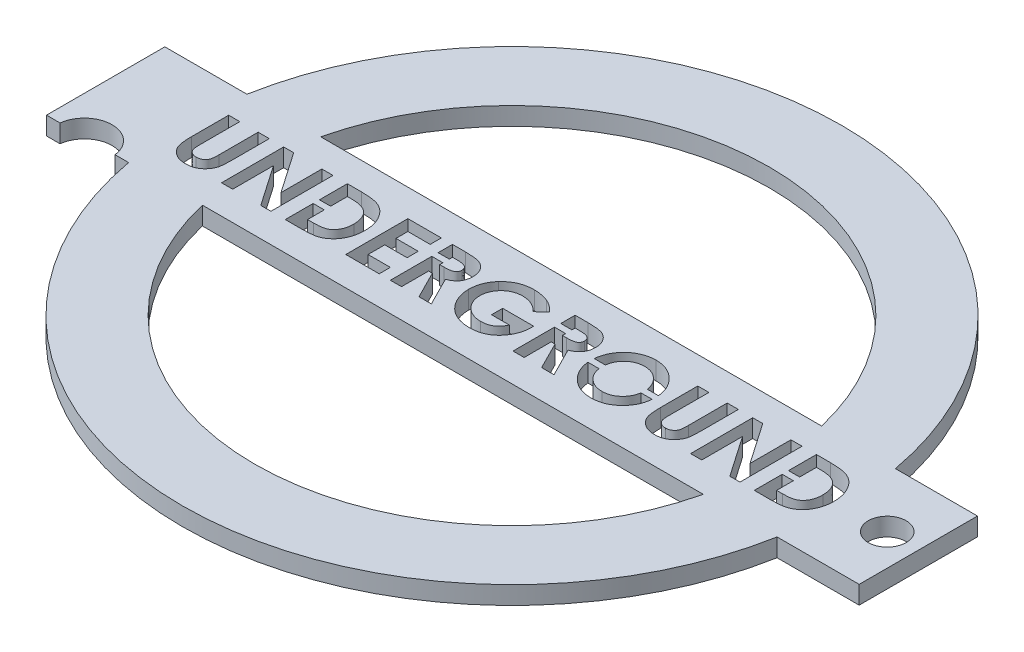
from build123d import *

# Parameters (mm, degrees)
BOSS_EXTRUDE1_DEPTH = 2
CUT_EXTRUDE1_DEPTH  = 2
SKETCH3_R           = 2.1
CUT_EXTRUDE2_DEPTH  = 2
SKETCH6_W           = 1.234722222
SKETCH6_H           = 0.7
BOSS_EXTRUDE3_DEPTH = 2


with BuildPart() as part:
    # Sketch1 → Boss-Extrude1 (new body)
    with BuildSketch(Plane(origin=(0, 0, 0), x_dir=(1, 0, 0), z_dir=(0, 1, 0))):
        with BuildLine():
            Line((4.544684747, 26.587817859), (13.63769066, 26.588010099))
            Line((13.63769066, 26.588010099), (13.63769066, 39.693010099))
            Line((13.63769066, 39.693010099), (4.544719829, 39.693010099))
            ThreePointArc((4.544719829, 39.693010099), (-31.36230934, 69.640510099), (-67.269338509, 39.693010099))
            Line((-67.269338509, 39.693010099), (-76.36230934, 39.693010099))
            Line((-76.36230934, 39.693010099), (-76.36230934, 26.588010099))
            Line((-76.36230934, 26.588010099), (-74.86230934, 26.588010099))
            ThreePointArc((-74.86230934, 26.588010099), (-71.815823925, 29.303985965), (-68.769338509, 26.588010099))
            Line((-68.769338509, 26.588010099), (-67.269338509, 26.588010099))
            ThreePointArc((-67.269338509, 26.588010099), (-31.362407048, -3.359489901), (4.544684747, 26.587817859))
        make_face()
        with BuildLine():
            Line((-59.098832983, 39.693010099), (-3.625785698, 39.693010099))
            ThreePointArc((-3.625785698, 39.693010099), (-31.36230934, 61.640510099), (-59.098832983, 39.693010099))
        make_face(mode=Mode.SUBTRACT)
        with BuildLine():
            Line((-59.098832983, 26.588010099), (-3.625785698, 26.588010099))
            ThreePointArc((-3.625785698, 26.588010099), (-31.36230934, 4.640510099), (-59.098832983, 26.588010099))
        make_face(mode=Mode.SUBTRACT)
    extrude(amount=BOSS_EXTRUDE1_DEPTH)

    # Sketch2 → Cut-Extrude1 (cut)
    with BuildSketch(Plane(origin=(0, 2, 0), x_dir=(1, 0, 0), z_dir=(0, 1, 0))):
        with BuildLine():
            Line((-66.26855934, 36.672176766), (-65.033837118, 36.672176766))
            Line((-65.033837118, 36.672176766), (-65.033837118, 32.19630871))
            add(Edge.make_bspline(
                [(-65.033837118, 32.19630871), (-65.03376998, 32.149904852), (-65.033640304, 32.060276278), (-65.027148628, 31.93168862), (-65.021208296, 31.813489638), (-65.010490253, 31.705808736), (-64.994656029, 31.608599852), (-64.979323333, 31.52123855), (-64.958572046, 31.445288935), (-64.927386179, 31.358838389), (-64.879338996, 31.261706479), (-64.800832563, 31.160473374), (-64.710242856, 31.068083472), (-64.601665875, 30.991181619), (-64.47963495, 30.928974951), (-64.344820588, 30.882886694), (-64.197412828, 30.857267742), (-64.095488448, 30.85335654), (-64.043027656, 30.851343432)],
                knots=[0, 0, 0, 0, 1.155499968, 2.231836252, 3.205919964, 4.102923608, 4.924856345, 5.658536265, 6.31071849, 6.882491295, 7.94666036, 8.992281882, 10.060072772, 11.158554251, 12.289267114, 13.461410017, 14.693379945, 16, 16, 16, 16], degree=3))
            add(Edge.make_bspline(
                [(-64.043027656, 30.851343432), (-63.98729454, 30.852969765), (-63.878624398, 30.856140838), (-63.722319699, 30.887268356), (-63.577502509, 30.936834024), (-63.447239102, 31.007576865), (-63.33165911, 31.092374558), (-63.233823069, 31.189070501), (-63.156611225, 31.297857554), (-63.106287418, 31.398221895), (-63.078033078, 31.490598531), (-63.056855043, 31.573133549), (-63.041329201, 31.670516702), (-63.027243646, 31.781227139), (-63.018779313, 31.90641161), (-63.009601123, 32.045063363), (-63.006237232, 32.198131092), (-63.005663881, 32.304715024), (-63.005364896, 32.360295255)],
                knots=[0, 0, 0, 0, 1.261321664, 2.459363699, 3.594844139, 4.716940403, 5.803436589, 6.833651888, 7.818396249, 8.814403945, 9.360733334, 10.004355033, 10.743453831, 11.592799886, 12.532235708, 13.585170094, 14.740740724, 16, 16, 16, 16], degree=3))
            Line((-63.005364896, 32.360295255), (-63.005364896, 36.672176766))
            Line((-63.005364896, 36.672176766), (-61.770642674, 36.672176766))
            Line((-61.770642674, 36.672176766), (-61.770642674, 32.568379023))
            add(Edge.make_bspline(
                [(-61.770642674, 32.568379023), (-61.770814137, 32.485236277), (-61.771143845, 32.325360884), (-61.776207163, 32.095608695), (-61.786986052, 31.885766924), (-61.796039075, 31.695774256), (-61.813559775, 31.525886642), (-61.831812234, 31.375378615), (-61.855076563, 31.24478354), (-61.889692487, 31.096116917), (-61.949429322, 30.924932746), (-62.045732933, 30.727821594), (-62.167984134, 30.534837837), (-62.312478943, 30.348104428), (-62.475626801, 30.174635109), (-62.653810369, 30.022351501), (-62.844198753, 29.89353599), (-63.048781377, 29.79133827), (-63.267384129, 29.711631753), (-63.50216992, 29.658072988), (-63.752978646, 29.621888014), (-63.926216973, 29.618412002), (-64.015466892, 29.61662121)],
                knots=[0, 0, 0, 0, 1.170808336, 2.251350247, 3.235597562, 4.129743112, 4.929140599, 5.639994148, 6.264258765, 6.79612947, 7.788252245, 8.809469599, 9.879094798, 10.999557536, 12.129761673, 13.226370002, 14.293821979, 15.358369427, 16.438775801, 17.562147481, 18.744053101, 20, 20, 20, 20], degree=3))
            add(Edge.make_bspline(
                [(-64.015466892, 29.61662121), (-64.074766314, 29.617620031), (-64.191762857, 29.619590683), (-64.363826798, 29.636966688), (-64.530160397, 29.662572386), (-64.690451113, 29.699928463), (-64.845255288, 29.748185537), (-64.994531792, 29.807586634), (-65.137725877, 29.877800422), (-65.274036251, 29.958181088), (-65.403295171, 30.04509894), (-65.521431152, 30.141451038), (-65.63250953, 30.240111781), (-65.733321297, 30.34523323), (-65.824623639, 30.455711791), (-65.906228519, 30.571797844), (-65.978014699, 30.693481077), (-66.041787922, 30.822954824), (-66.096371576, 30.966799768), (-66.142387647, 31.130132532), (-66.182588369, 31.315513196), (-66.212463174, 31.523359411), (-66.239547848, 31.752986139), (-66.256690953, 32.004991594), (-66.265659283, 32.279383006), (-66.267568228, 32.469612883), (-66.26855934, 32.568379023)],
                knots=[0, 0, 0, 0, 1.001158378, 1.975264943, 2.917723546, 3.841610987, 4.75185031, 5.653588123, 6.552117133, 7.442167995, 8.324307438, 9.179605724, 10.014504199, 10.831958861, 11.636465792, 12.43274043, 13.225645099, 14.020104002, 14.867201867, 15.819789774, 16.883317127, 18.068162734, 19.364263498, 20.787406516, 22.332041935, 24, 24, 24, 24], degree=3))
            Line((-66.26855934, 32.568379023), (-66.26855934, 36.672176766))
        make_face()
        Polygon((-60.183142674, 36.672176766), (-59.071065851, 36.672176766), (-55.94980934, 32.145321297), (-55.94980934, 36.672176766), (-54.715087118, 36.672176766), (-54.715087118, 29.793010099), (-55.83543217, 29.793010099), (-58.948420451, 34.306085186), (-58.948420451, 29.793010099), (-60.183142674, 29.793010099), align=None)
        with BuildLine():
            Line((-53.127587118, 36.672176766), (-51.571781997, 36.672176766))
            add(Edge.make_bspline(
                [(-51.571781997, 36.672176766), (-51.450489093, 36.671328887), (-51.216028537, 36.669689927), (-50.876341577, 36.651222795), (-50.56047593, 36.622821656), (-50.268227983, 36.583750743), (-50.000196892, 36.532049226), (-49.756728276, 36.467199806), (-49.537004998, 36.392341939), (-49.338617836, 36.304256468), (-49.157509439, 36.201557557), (-48.985541236, 36.087159215), (-48.823050882, 35.956870697), (-48.667758083, 35.813205528), (-48.521666925, 35.653535397), (-48.382344466, 35.480505021), (-48.253201953, 35.29160522), (-48.130335687, 35.091365216), (-48.019219498, 34.878936411), (-47.922299807, 34.656126955), (-47.841109594, 34.424370709), (-47.775138341, 34.183420681), (-47.722551639, 33.934076753), (-47.685757783, 33.675835772), (-47.663011455, 33.408936825), (-47.66070403, 33.228046304), (-47.659531563, 33.136130759)],
                knots=[0, 0, 0, 0, 1.44355588, 2.790409838, 4.047694926, 5.217575253, 6.298404546, 7.294384826, 8.214239204, 9.058592145, 9.873746385, 10.689560431, 11.514393297, 12.350027578, 13.205127629, 14.088021785, 14.991911688, 15.926770944, 16.882954281, 17.842803888, 18.816321264, 19.80318086, 20.814351908, 21.847355356, 22.906180909, 24, 24, 24, 24], degree=3))
            add(Edge.make_bspline(
                [(-47.659531563, 33.136130759), (-47.662601715, 33.006431942), (-47.668645489, 32.751112229), (-47.719554867, 32.376433492), (-47.80189257, 32.017266553), (-47.917666858, 31.676420955), (-48.061195983, 31.356931977), (-48.232657595, 31.064433675), (-48.429537667, 30.800496031), (-48.649542536, 30.566433238), (-48.887754227, 30.365253095), (-49.135304209, 30.192957025), (-49.394604071, 30.057087196), (-49.623083488, 29.970925407), (-49.821203646, 29.917340229), (-49.995151002, 29.885670873), (-50.19273745, 29.856628163), (-50.415805312, 29.834184581), (-50.663376037, 29.814170422), (-50.936436446, 29.803295507), (-51.234102447, 29.794260067), (-51.44085963, 29.793437672), (-51.548355347, 29.793010099)],
                knots=[0, 0, 0, 0, 1.315458931, 2.589557908, 3.828601765, 5.048913369, 6.235739168, 7.376350998, 8.481830359, 9.569842114, 10.627874879, 11.640079404, 12.624025415, 13.590060155, 14.111227486, 14.704434459, 15.382649715, 16.137166398, 16.978595427, 17.902333227, 18.909396075, 20, 20, 20, 20], degree=3))
            Line((-51.548355347, 29.793010099), (-53.127587118, 29.793010099))
            Line((-53.127587118, 29.793010099), (-53.127587118, 36.672176766))
        make_face()
        with BuildLine():
            Line((-51.892864896, 35.437454544), (-51.892864896, 31.027732321))
            Line((-51.892864896, 31.027732321), (-51.247943021, 31.027732321))
            add(Edge.make_bspline(
                [(-51.247943021, 31.027732321), (-51.171207222, 31.027872933), (-51.023618736, 31.028143376), (-50.81053437, 31.04102482), (-50.613485361, 31.053954237), (-50.433014138, 31.078494703), (-50.267807288, 31.105831055), (-50.12013432, 31.143873332), (-49.986951054, 31.183833522), (-49.869884296, 31.234707796), (-49.762660685, 31.291970178), (-49.663383868, 31.359059696), (-49.567553944, 31.433560076), (-49.476962532, 31.517662479), (-49.391266763, 31.610253233), (-49.31097367, 31.711809416), (-49.23501155, 31.822021176), (-49.165330209, 31.941471231), (-49.101655026, 32.068898162), (-49.045168004, 32.203067653), (-48.998331927, 32.345097046), (-48.959404648, 32.493656776), (-48.931586692, 32.650040224), (-48.90857264, 32.813089079), (-48.896708226, 32.983449328), (-48.895079909, 33.099368134), (-48.894253785, 33.15817937)],
                knots=[0, 0, 0, 0, 1.50275155, 2.890291501, 4.180787663, 5.369391935, 6.45668281, 7.458360028, 8.354766181, 9.177074746, 9.954075863, 10.732690366, 11.5210699, 12.329727389, 13.151100085, 13.990027547, 14.863562427, 15.770965086, 16.696477834, 17.652329173, 18.619756807, 19.62365428, 20.657822005, 21.729286259, 22.847956731, 24, 24, 24, 24], degree=3))
            add(Edge.make_bspline(
                [(-48.894253785, 33.15817937), (-48.895899144, 33.248302029), (-48.899107466, 33.424034231), (-48.930047833, 33.679992019), (-48.980412849, 33.92101462), (-49.052278874, 34.146207536), (-49.142868225, 34.356203676), (-49.256261915, 34.549223928), (-49.387579917, 34.728510767), (-49.491422609, 34.83368618), (-49.543309774, 34.886239266)],
                knots=[0, 0, 0, 0, 1.13821349, 2.219428113, 3.251817212, 4.244760574, 5.201143372, 6.134805572, 7.068016741, 8, 8, 8, 8], degree=3))
            add(Edge.make_bspline(
                [(-49.543309774, 34.886239266), (-49.594475432, 34.9310216), (-49.698975495, 35.022484446), (-49.882443264, 35.132080326), (-50.084615244, 35.228371049), (-50.310116523, 35.304718854), (-50.556767731, 35.365097953), (-50.826037929, 35.406739941), (-51.116485115, 35.433498641), (-51.317700158, 35.436107659), (-51.421575833, 35.437454544)],
                knots=[0, 0, 0, 0, 0.813307809, 1.661089106, 2.549956539, 3.493439533, 4.508053171, 5.589449661, 6.755572447, 8, 8, 8, 8], degree=3))
            Line((-51.421575833, 35.437454544), (-51.892864896, 35.437454544))
        make_face(mode=Mode.SUBTRACT)
        Polygon((-46.42480934, 36.672176766), (-42.720642674, 36.672176766), (-42.720642674, 35.437454544), (-45.190087118, 35.437454544), (-45.190087118, 34.114537877), (-42.720642674, 34.114537877), (-42.720642674, 32.879815655), (-45.190087118, 32.879815655), (-45.190087118, 31.027732321), (-42.720642674, 31.027732321), (-42.720642674, 29.793010099), (-46.42480934, 29.793010099), align=None)
        with BuildLine():
            Line((-41.485920451, 36.672176766), (-40.047248576, 36.672176766))
            add(Edge.make_bspline(
                [(-40.047248576, 36.672176766), (-39.952152803, 36.67183923), (-39.769256845, 36.671190055), (-39.505530862, 36.660947782), (-39.263262279, 36.646694819), (-39.042092394, 36.624944419), (-38.842115829, 36.596106017), (-38.663132159, 36.562110314), (-38.505146616, 36.523364922), (-38.366826811, 36.475085106), (-38.242000026, 36.420626206), (-38.125644109, 36.358051931), (-38.015192074, 36.288059066), (-37.911382174, 36.208805909), (-37.813312276, 36.121718204), (-37.720797367, 36.02670829), (-37.635144767, 35.922970521), (-37.556884841, 35.811160389), (-37.485557218, 35.693538693), (-37.422518559, 35.56994394), (-37.371255416, 35.440290176), (-37.325958935, 35.306451179), (-37.293333347, 35.166513695), (-37.270642728, 35.021840038), (-37.254029544, 34.871920941), (-37.253074365, 34.770072563), (-37.252587118, 34.718118606)],
                knots=[0, 0, 0, 0, 1.749336639, 3.364467119, 4.854658419, 6.213483162, 7.451590619, 8.570285859, 9.5643256, 10.440900261, 11.26203566, 12.067320669, 12.869050712, 13.665104639, 14.467235401, 15.27997916, 16.102287765, 16.939272006, 17.78853747, 18.631303466, 19.488103222, 20.351255419, 21.228522269, 22.127379805, 23.044756219, 24, 24, 24, 24], degree=3))
            add(Edge.make_bspline(
                [(-37.252587118, 34.718118606), (-37.25385281, 34.66389061), (-37.256334602, 34.557559392), (-37.269702884, 34.401367506), (-37.294135904, 34.251934035), (-37.331143266, 34.109696501), (-37.373678423, 33.972884593), (-37.43023927, 33.844022576), (-37.494073777, 33.721236337), (-37.569888155, 33.606262737), (-37.653090732, 33.49654798), (-37.749853578, 33.396295646), (-37.853907948, 33.300117552), (-37.971103116, 33.214037968), (-38.096273011, 33.132236502), (-38.231904628, 33.05810259), (-38.377112787, 32.989772675), (-38.479201313, 32.951667195), (-38.531406563, 32.932181106)],
                knots=[0, 0, 0, 0, 1.099860209, 2.156625411, 3.176576793, 4.16617041, 5.135385252, 6.078461593, 7.016046972, 7.938469504, 8.868247731, 9.803980173, 10.76021508, 11.73834243, 12.748633912, 13.790971185, 14.870363756, 16, 16, 16, 16], degree=3))
            Line((-38.531406563, 32.932181106), (-36.943906563, 29.793010099))
            Line((-36.943906563, 29.793010099), (-38.316432604, 29.793010099))
            Line((-38.316432604, 29.793010099), (-39.832274618, 32.79162121))
            Line((-39.832274618, 32.79162121), (-40.251198229, 32.79162121))
            Line((-40.251198229, 32.79162121), (-40.251198229, 29.793010099))
            Line((-40.251198229, 29.793010099), (-41.485920451, 29.793010099))
            Line((-41.485920451, 29.793010099), (-41.485920451, 36.672176766))
        make_face()
        with BuildLine():
            Line((-40.251198229, 34.026343432), (-39.770262899, 34.026343432))
            add(Edge.make_bspline(
                [(-39.770262899, 34.026343432), (-39.711464558, 34.027005659), (-39.598878367, 34.02827368), (-39.436964638, 34.034155289), (-39.289908358, 34.048327059), (-39.157078017, 34.066232562), (-39.037805225, 34.08690705), (-38.933153854, 34.116534847), (-38.841511385, 34.148281781), (-38.763963785, 34.187734985), (-38.697708898, 34.232601835), (-38.640502043, 34.283571692), (-38.593183772, 34.342562812), (-38.554238422, 34.407972069), (-38.523943173, 34.480377994), (-38.501829962, 34.558985733), (-38.489471948, 34.644690729), (-38.488050116, 34.703838846), (-38.48730934, 34.734655064)],
                knots=[0, 0, 0, 0, 1.688639943, 3.233382647, 4.650958383, 5.928841754, 7.082724185, 8.122798841, 9.049171256, 9.863274652, 10.613301712, 11.341792392, 12.054588806, 12.776240173, 13.521029143, 14.301969904, 15.115324896, 16, 16, 16, 16], degree=3))
            add(Edge.make_bspline(
                [(-38.48730934, 34.734655064), (-38.488709844, 34.771112901), (-38.491460875, 34.842727564), (-38.518759644, 34.945827568), (-38.562213387, 35.041253676), (-38.621776568, 35.128574728), (-38.69678865, 35.205126391), (-38.782870933, 35.272607291), (-38.881881279, 35.325966138), (-38.97355741, 35.361161065), (-39.05696126, 35.382218553), (-39.132230603, 35.397910407), (-39.219392955, 35.409031674), (-39.31851412, 35.420827758), (-39.429341434, 35.428476921), (-39.552478972, 35.434059285), (-39.687573084, 35.436343304), (-39.781746511, 35.437073465), (-39.83089658, 35.437454544)],
                knots=[0, 0, 0, 0, 1.020303359, 2.004196876, 2.966617323, 3.9489082, 4.950758222, 5.960522915, 7.003732012, 8.091992268, 8.70421221, 9.413913587, 10.24622431, 11.166358409, 12.212345909, 13.359657661, 14.621978493, 16, 16, 16, 16], degree=3))
            Line((-39.83089658, 35.437454544), (-40.251198229, 35.437454544))
            Line((-40.251198229, 35.437454544), (-40.251198229, 34.026343432))
        make_face(mode=Mode.SUBTRACT)
        with BuildLine():
            Line((-29.625145712, 35.578014439), (-30.559455608, 34.683667651))
            add(Edge.make_bspline(
                [(-30.559455608, 34.683667651), (-30.633426553, 34.757727226), (-30.778569758, 34.903044339), (-31.015933315, 35.092184548), (-31.261769921, 35.252991118), (-31.516888725, 35.385217527), (-31.781645108, 35.487783826), (-32.055516593, 35.561152782), (-32.338948732, 35.604669152), (-32.530819639, 35.610761296), (-32.627890938, 35.613843432)],
                knots=[0, 0, 0, 0, 1.075575784, 2.110457258, 3.113929901, 4.09197124, 5.059417775, 6.02750972, 7.002078037, 8, 8, 8, 8], degree=3))
            add(Edge.make_bspline(
                [(-32.627890938, 35.613843432), (-32.712048785, 35.611683793), (-32.877300097, 35.607443153), (-33.120120983, 35.575240019), (-33.352151214, 35.521446133), (-33.574486996, 35.446923685), (-33.785770893, 35.349946428), (-33.987227123, 35.23201109), (-34.177615921, 35.092215457), (-34.355438115, 34.933209568), (-34.517345794, 34.759607242), (-34.658699747, 34.573791365), (-34.779102947, 34.379225389), (-34.878219337, 34.174913885), (-34.953636131, 33.961170432), (-35.007473854, 33.738150195), (-35.04164742, 33.506501303), (-35.045682297, 33.34846803), (-35.047726007, 33.268422425)],
                knots=[0, 0, 0, 0, 1.075001177, 2.110859044, 3.123021556, 4.114053297, 5.101481495, 6.087880186, 7.091499647, 8.114004866, 9.131394192, 10.11971144, 11.092043119, 12.050101265, 13.015322563, 13.981809771, 14.977764287, 16, 16, 16, 16], degree=3))
            add(Edge.make_bspline(
                [(-35.047726007, 33.268422425), (-35.045819732, 33.185606336), (-35.042064109, 33.022447301), (-35.005987108, 32.783004405), (-34.950404276, 32.552643084), (-34.86904583, 32.333072567), (-34.768918222, 32.121285043), (-34.641939919, 31.921383039), (-34.49387051, 31.730313832), (-34.324974576, 31.551404047), (-34.141259416, 31.386492282), (-33.94228992, 31.244235148), (-33.734119961, 31.121497949), (-33.513389665, 31.024294055), (-33.283930257, 30.946249977), (-33.04341436, 30.891222204), (-32.792383558, 30.857462857), (-32.621107504, 30.853403546), (-32.53418434, 30.851343432)],
                knots=[0, 0, 0, 0, 1.022067601, 2.013613092, 2.983553406, 3.943623673, 4.90013463, 5.87121881, 6.861774014, 7.881098904, 8.905697761, 9.905387765, 10.89678721, 11.884561068, 12.87834324, 13.885584958, 14.926927371, 16, 16, 16, 16], degree=3))
            add(Edge.make_bspline(
                [(-32.53418434, 30.851343432), (-32.477644041, 30.851853586), (-32.366642854, 30.85285513), (-32.203823028, 30.869113014), (-32.047880742, 30.89235555), (-31.898212075, 30.923125906), (-31.756328279, 30.966671483), (-31.620264876, 31.017592672), (-31.490819076, 31.077689828), (-31.368692723, 31.149036416), (-31.252068221, 31.22900722), (-31.142037199, 31.320510825), (-31.036669583, 31.421484162), (-30.93719658, 31.533160764), (-30.845301799, 31.656539151), (-30.758041165, 31.78935208), (-30.676413797, 31.93291764), (-30.628182339, 32.034296366), (-30.60355283, 32.086065655)],
                knots=[0, 0, 0, 0, 1.109579412, 2.178351274, 3.208885622, 4.204702371, 5.174744997, 6.119429583, 7.05542196, 7.97267548, 8.893247984, 9.828544973, 10.778894627, 11.756245826, 12.760884819, 13.796418446, 14.874735809, 16, 16, 16, 16], degree=3))
            Line((-30.60355283, 32.086065655), (-32.578281563, 32.086065655))
            Line((-32.578281563, 32.086065655), (-32.578281563, 33.320787877))
            Line((-32.578281563, 33.320787877), (-29.148344497, 33.320787877))
            Line((-29.148344497, 33.320787877), (-29.138698229, 33.027265741))
            add(Edge.make_bspline(
                [(-29.138698229, 33.027265741), (-29.139937703, 32.95188181), (-29.142414438, 32.801248475), (-29.1650492, 32.576981101), (-29.202543338, 32.355688169), (-29.253801415, 32.13759194), (-29.318040751, 31.921622573), (-29.399966013, 31.709848155), (-29.495899995, 31.500832503), (-29.603387215, 31.29546377), (-29.724171925, 31.098406888), (-29.854214399, 30.911820033), (-29.991660796, 30.736026148), (-30.139500515, 30.573474481), (-30.295431451, 30.422799527), (-30.459760555, 30.284580951), (-30.63306905, 30.158701802), (-30.814438852, 30.04409869), (-31.004903037, 29.943655823), (-31.203414433, 29.856283855), (-31.409673315, 29.782080687), (-31.624212196, 29.721250231), (-31.846608915, 29.674314695), (-32.076868237, 29.642130936), (-32.315116625, 29.62026171), (-32.476715466, 29.617849381), (-32.558989028, 29.61662121)],
                knots=[0, 0, 0, 0, 1.006889344, 2.011981806, 3.007738725, 4.003571281, 5.003404394, 6.015442001, 7.03424805, 8.074616296, 9.110249922, 10.119753985, 11.111721717, 12.089233633, 13.052717867, 14.006597561, 14.955430184, 15.912305663, 16.870361111, 17.829300583, 18.807640451, 19.796414044, 20.806216501, 21.841577364, 22.90109906, 24, 24, 24, 24], degree=3))
            add(Edge.make_bspline(
                [(-32.558989028, 29.61662121), (-32.64676934, 29.617834051), (-32.820776102, 29.620238265), (-33.078068419, 29.642755357), (-33.327896526, 29.679918364), (-33.570322736, 29.731350697), (-33.805909914, 29.795362343), (-34.034253284, 29.875712101), (-34.254885822, 29.971290678), (-34.46846822, 30.079567118), (-34.672270662, 30.202362033), (-34.865836394, 30.337522199), (-35.048108897, 30.485917039), (-35.220955207, 30.645062393), (-35.380336966, 30.818870067), (-35.532193709, 31.001706113), (-35.669168496, 31.200276226), (-35.797150838, 31.408142706), (-35.910851373, 31.625218445), (-36.010284126, 31.847488516), (-36.09508032, 32.073665973), (-36.16194417, 32.304803976), (-36.216231353, 32.539290836), (-36.255074852, 32.778146283), (-36.277011591, 33.021340416), (-36.280627971, 33.184779471), (-36.282448229, 33.267044387)],
                knots=[0, 0, 0, 0, 1.084149091, 2.14910686, 3.187506334, 4.202448172, 5.208724393, 6.201130722, 7.189831603, 8.176984443, 9.156919086, 10.126598231, 11.090766514, 12.05840148, 13.026036446, 14.001772938, 14.991905635, 16.003017641, 17.015720547, 18.016462227, 19.009322657, 19.99686681, 20.986544154, 21.980959929, 22.983742515, 24, 24, 24, 24], degree=3))
            add(Edge.make_bspline(
                [(-36.282448229, 33.267044387), (-36.280010515, 33.379271313), (-36.275196752, 33.600886219), (-36.230614003, 33.92732638), (-36.161116139, 34.243124665), (-36.061379707, 34.547130956), (-35.933394313, 34.839764026), (-35.778972985, 35.121710846), (-35.594761358, 35.392671729), (-35.452168906, 35.560434149), (-35.379833212, 35.645538311)],
                knots=[0, 0, 0, 0, 1.034044851, 2.041932006, 3.031217818, 4.011390712, 4.986069675, 5.97149666, 6.970960976, 8, 8, 8, 8], degree=3))
            add(Edge.make_bspline(
                [(-35.379833212, 35.645538311), (-35.334920686, 35.694773648), (-35.245769998, 35.792505052), (-35.103262785, 35.928304826), (-34.95714155, 36.055961637), (-34.805382489, 36.172768604), (-34.648783372, 36.281282686), (-34.486893479, 36.3794697), (-34.320562048, 36.470455974), (-34.148491894, 36.549595403), (-33.971583828, 36.620550503), (-33.789054353, 36.680588494), (-33.602270577, 36.733767884), (-33.409578523, 36.77422376), (-33.21292484, 36.807912327), (-33.010913616, 36.830492168), (-32.804095342, 36.847041585), (-32.664213863, 36.848053613), (-32.593439983, 36.848565655)],
                knots=[0, 0, 0, 0, 1.020590567, 2.025856924, 3.013483481, 3.991664875, 4.957826714, 5.930500614, 6.890802512, 7.860442893, 8.829981142, 9.809047939, 10.802672283, 11.803273349, 12.823572789, 13.857849586, 14.916166035, 16, 16, 16, 16], degree=3))
            add(Edge.make_bspline(
                [(-32.593439983, 36.848565655), (-32.5194583, 36.84742473), (-32.372261916, 36.845154708), (-32.153405269, 36.829447642), (-31.937589782, 36.80521534), (-31.725724923, 36.768865503), (-31.517099672, 36.724038589), (-31.312793922, 36.666604217), (-31.111474833, 36.601348425), (-30.980416868, 36.549321687), (-30.914989462, 36.523348641)],
                knots=[0, 0, 0, 0, 1.03180557, 2.052914215, 3.058998889, 4.059601663, 5.049854447, 6.033765722, 7.018406786, 8, 8, 8, 8], degree=3))
            add(Edge.make_bspline(
                [(-30.914989462, 36.523348641), (-30.859940393, 36.499344871), (-30.74797211, 36.450521868), (-30.585072058, 36.361197893), (-30.421773996, 36.262172015), (-30.259839994, 36.149823618), (-30.099516794, 36.024362846), (-29.939130451, 35.88777133), (-29.780318246, 35.738456335), (-29.677539755, 35.632187683), (-29.625145712, 35.578014439)],
                knots=[0, 0, 0, 0, 0.894392155, 1.819168899, 2.76525314, 3.739198753, 4.75366411, 5.797420238, 6.877176959, 8, 8, 8, 8], degree=3))
        make_face()
        with BuildLine():
            Line((-27.903976007, 36.672176766), (-26.465304132, 36.672176766))
            add(Edge.make_bspline(
                [(-26.465304132, 36.672176766), (-26.370208359, 36.67183923), (-26.1873124, 36.671190055), (-25.923586418, 36.660947782), (-25.681317835, 36.646694819), (-25.46014795, 36.624944419), (-25.260171384, 36.596106017), (-25.081187715, 36.562110314), (-24.923202172, 36.523364922), (-24.784882366, 36.475085106), (-24.660055582, 36.420626206), (-24.543699664, 36.358051931), (-24.433247629, 36.288059066), (-24.329437729, 36.208805909), (-24.231367832, 36.121718204), (-24.138852923, 36.02670829), (-24.053200323, 35.922970521), (-23.974940397, 35.811160389), (-23.903612773, 35.693538693), (-23.840574114, 35.56994394), (-23.789310972, 35.440290176), (-23.744014491, 35.306451179), (-23.711388902, 35.166513695), (-23.688698283, 35.021840038), (-23.672085099, 34.871920941), (-23.671129921, 34.770072563), (-23.670642674, 34.718118606)],
                knots=[0, 0, 0, 0, 1.749336639, 3.364467119, 4.854658419, 6.213483162, 7.451590619, 8.570285859, 9.5643256, 10.440900261, 11.26203566, 12.067320669, 12.869050712, 13.665104639, 14.467235401, 15.27997916, 16.102287765, 16.939272006, 17.78853747, 18.631303466, 19.488103222, 20.351255419, 21.228522269, 22.127379805, 23.044756219, 24, 24, 24, 24], degree=3))
            add(Edge.make_bspline(
                [(-23.670642674, 34.718118606), (-23.671908366, 34.66389061), (-23.674390158, 34.557559392), (-23.68775844, 34.401367506), (-23.712191459, 34.251934035), (-23.749198822, 34.109696501), (-23.791733979, 33.972884593), (-23.848294826, 33.844022576), (-23.912129332, 33.721236337), (-23.987943711, 33.606262737), (-24.071146287, 33.49654798), (-24.167909133, 33.396295646), (-24.271963503, 33.300117552), (-24.389158672, 33.214037968), (-24.514328567, 33.132236502), (-24.649960183, 33.05810259), (-24.795168342, 32.989772675), (-24.897256869, 32.951667195), (-24.949462118, 32.932181106)],
                knots=[0, 0, 0, 0, 1.099860209, 2.156625411, 3.176576793, 4.16617041, 5.135385252, 6.078461593, 7.016046972, 7.938469504, 8.868247731, 9.803980173, 10.76021508, 11.73834243, 12.748633912, 13.790971185, 14.870363756, 16, 16, 16, 16], degree=3))
            Line((-24.949462118, 32.932181106), (-23.361962118, 29.793010099))
            Line((-23.361962118, 29.793010099), (-24.73448816, 29.793010099))
            Line((-24.73448816, 29.793010099), (-26.250330174, 32.79162121))
            Line((-26.250330174, 32.79162121), (-26.669253785, 32.79162121))
            Line((-26.669253785, 32.79162121), (-26.669253785, 29.793010099))
            Line((-26.669253785, 29.793010099), (-27.903976007, 29.793010099))
            Line((-27.903976007, 29.793010099), (-27.903976007, 36.672176766))
        make_face()
        with BuildLine():
            Line((-26.669253785, 34.026343432), (-26.188318455, 34.026343432))
            add(Edge.make_bspline(
                [(-26.188318455, 34.026343432), (-26.129520113, 34.027005659), (-26.016933923, 34.02827368), (-25.855020194, 34.034155289), (-25.707963913, 34.048327059), (-25.575133572, 34.066232562), (-25.45586078, 34.08690705), (-25.351209409, 34.116534847), (-25.25956694, 34.148281781), (-25.182019341, 34.187734985), (-25.115764453, 34.232601835), (-25.058557599, 34.283571692), (-25.011239328, 34.342562812), (-24.972293977, 34.407972069), (-24.941998728, 34.480377994), (-24.919885518, 34.558985733), (-24.907527503, 34.644690729), (-24.906105671, 34.703838846), (-24.905364896, 34.734655064)],
                knots=[0, 0, 0, 0, 1.688639943, 3.233382647, 4.650958383, 5.928841754, 7.082724185, 8.122798841, 9.049171256, 9.863274652, 10.613301712, 11.341792392, 12.054588806, 12.776240173, 13.521029143, 14.301969904, 15.115324896, 16, 16, 16, 16], degree=3))
            add(Edge.make_bspline(
                [(-24.905364896, 34.734655064), (-24.9067654, 34.771112901), (-24.90951643, 34.842727564), (-24.936815199, 34.945827568), (-24.980268943, 35.041253676), (-25.039832123, 35.128574728), (-25.114844206, 35.205126391), (-25.200926488, 35.272607291), (-25.299936835, 35.325966138), (-25.391612965, 35.361161065), (-25.475016815, 35.382218553), (-25.550286158, 35.397910407), (-25.637448511, 35.409031674), (-25.736569676, 35.420827758), (-25.84739699, 35.428476921), (-25.970534528, 35.434059285), (-26.10562864, 35.436343304), (-26.199802067, 35.437073465), (-26.248952136, 35.437454544)],
                knots=[0, 0, 0, 0, 1.020303359, 2.004196876, 2.966617323, 3.9489082, 4.950758222, 5.960522915, 7.003732012, 8.091992268, 8.70421221, 9.413913587, 10.24622431, 11.166358409, 12.212345909, 13.359657661, 14.621978493, 16, 16, 16, 16], degree=3))
            Line((-26.248952136, 35.437454544), (-26.669253785, 35.437454544))
            Line((-26.669253785, 35.437454544), (-26.669253785, 34.026343432))
        make_face(mode=Mode.SUBTRACT)
        with BuildLine():
            add(Edge.make_bspline(
                [(-19.114848403, 36.848565655), (-18.99524566, 36.845468925), (-18.759122755, 36.839355281), (-18.41187117, 36.788393279), (-18.077230061, 36.705358004), (-17.755350752, 36.589932966), (-17.447039192, 36.438991868), (-17.151207862, 36.256813989), (-16.868916418, 36.039960832), (-16.603057554, 35.793491222), (-16.357356015, 35.525466283), (-16.144455488, 35.236889785), (-15.962901729, 34.935239035), (-15.812429487, 34.619705752), (-15.697816868, 34.288104716), (-15.617388453, 33.942126654), (-15.565717181, 33.581869995), (-15.559774189, 33.336584313), (-15.556753785, 33.211922859)],
                knots=[0, 0, 0, 0, 1.014329547, 2.002516266, 2.970391464, 3.935626869, 4.897733899, 5.877609409, 6.878433252, 7.912639331, 8.949961323, 9.958554974, 10.949718813, 11.932905612, 12.9188844, 13.919928257, 14.942845884, 16, 16, 16, 16], degree=3))
            add(Edge.make_bspline(
                [(-15.556753785, 33.211922859), (-15.559970385, 33.088666052), (-15.566308798, 32.845784559), (-15.615279005, 32.488847807), (-15.697061845, 32.146575891), (-15.809730545, 31.818194072), (-15.957473788, 31.505292918), (-16.135487051, 31.205874599), (-16.348467765, 30.922717789), (-16.588647687, 30.655974441), (-16.853064937, 30.413847615), (-17.133124781, 30.200473768), (-17.427534075, 30.019668822), (-17.735861898, 29.871515595), (-18.058769443, 29.756539332), (-18.395459091, 29.675415223), (-18.745910007, 29.626114464), (-18.984233624, 29.619817453), (-19.105202136, 29.61662121)],
                knots=[0, 0, 0, 0, 1.051557043, 2.072126891, 3.067553643, 4.050577992, 5.02905126, 6.015227836, 7.017913613, 8.04756643, 9.074058332, 10.072836633, 11.047628519, 12.017157415, 12.98668631, 13.966869689, 14.968021931, 16, 16, 16, 16], degree=3))
            add(Edge.make_bspline(
                [(-19.105202136, 29.61662121), (-19.231720693, 29.619488397), (-19.480312366, 29.625122028), (-19.844127392, 29.678695287), (-20.192693623, 29.759395328), (-20.523082902, 29.879835811), (-20.838659962, 30.030396542), (-21.137106165, 30.215821109), (-21.418321214, 30.435803084), (-21.680692012, 30.684708646), (-21.918400591, 30.957065924), (-22.128225039, 31.244787236), (-22.305216615, 31.545674644), (-22.449381796, 31.85986897), (-22.563035833, 32.185417572), (-22.643205843, 32.524303135), (-22.69056418, 32.87571289), (-22.697160922, 33.11439742), (-22.700503785, 33.235349509)],
                knots=[0, 0, 0, 0, 1.067978421, 2.098431617, 3.099715153, 4.085208694, 5.062210972, 6.048429807, 7.046490867, 8.072918869, 9.098532598, 10.095778865, 11.076610158, 12.041847152, 13.011192615, 13.984257998, 14.978533688, 16, 16, 16, 16], degree=3))
            add(Edge.make_bspline(
                [(-22.700503785, 33.235349509), (-22.699454602, 33.316719743), (-22.697369521, 33.478429876), (-22.672252526, 33.71807604), (-22.636091274, 33.953044632), (-22.582610498, 34.18239883), (-22.517645025, 34.40775662), (-22.433473077, 34.627020317), (-22.337662621, 34.84253226), (-22.225717125, 35.051746982), (-22.101244557, 35.252739534), (-21.965433904, 35.444561799), (-21.81794367, 35.624894365), (-21.659248972, 35.794922304), (-21.488802925, 35.953528008), (-21.308847571, 36.102956764), (-21.115892825, 36.239239212), (-20.91416186, 36.365703641), (-20.70479199, 36.480063231), (-20.488635538, 36.577402693), (-20.270145756, 36.662407588), (-20.046403914, 36.72949721), (-19.819807805, 36.784141005), (-19.587936707, 36.820277884), (-19.352885445, 36.845394183), (-19.194382387, 36.847505989), (-19.114848403, 36.848565655)],
                knots=[0, 0, 0, 0, 1.034744296, 2.056386356, 3.06226378, 4.057406941, 5.050368692, 6.043467995, 7.042652155, 8.049140477, 9.059438543, 10.048523776, 11.036952808, 12.020949711, 13.004946614, 13.997082645, 14.994316842, 16.007702937, 17.024872941, 18.026463647, 19.021641123, 20.005082605, 20.995858141, 21.984425357, 22.988620895, 24, 24, 24, 24], degree=3))
        make_face()
        with BuildLine():
            add(Edge.make_bspline(
                [(-19.134140938, 35.613843432), (-19.214633568, 35.611683634), (-19.37349381, 35.607421057), (-19.606512855, 35.574945986), (-19.830219366, 35.523079606), (-20.043373252, 35.447951788), (-20.246898338, 35.352333143), (-20.441155413, 35.236557775), (-20.623454417, 35.096646034), (-20.796226131, 34.940109158), (-20.952296944, 34.765691104), (-21.090190432, 34.578772496), (-21.20558507, 34.379665486), (-21.302228803, 34.17021973), (-21.374980115, 33.948080066), (-21.426798693, 33.714986538), (-21.4595461, 33.470537514), (-21.463673951, 33.303896933), (-21.465781563, 33.21881305)],
                knots=[0, 0, 0, 0, 1.033739768, 2.040188636, 3.016340934, 3.979330865, 4.937572243, 5.900995986, 6.878200029, 7.884839167, 8.891893314, 9.879764717, 10.863503415, 11.843163062, 12.837761627, 13.859916423, 14.907309254, 16, 16, 16, 16], degree=3))
            add(Edge.make_bspline(
                [(-21.465781563, 33.21881305), (-21.462987191, 33.124520969), (-21.457510687, 32.939724112), (-21.418977335, 32.670147436), (-21.353050605, 32.415559021), (-21.257853689, 32.177204021), (-21.139784538, 31.952435682), (-20.993161392, 31.74400886), (-20.82035885, 31.550675592), (-20.687233172, 31.437799577), (-20.619666111, 31.380510099)],
                knots=[0, 0, 0, 0, 1.078454662, 2.113592447, 3.107694534, 4.079536787, 5.043276885, 6.005368276, 6.987637804, 8, 8, 8, 8], degree=3))
            add(Edge.make_bspline(
                [(-20.619666111, 31.380510099), (-20.564315789, 31.338186833), (-20.454862196, 31.254493851), (-20.280150432, 31.147224126), (-20.100231718, 31.055283271), (-19.91374834, 30.980996148), (-19.721094144, 30.922563145), (-19.522295546, 30.881643474), (-19.317634229, 30.855962842), (-19.179232654, 30.85289352), (-19.10933625, 30.851343432)],
                knots=[0, 0, 0, 0, 1.023928204, 2.024787132, 3.009472467, 3.9914905, 4.972207045, 5.96565515, 6.972602802, 8, 8, 8, 8], degree=3))
            add(Edge.make_bspline(
                [(-19.10933625, 30.851343432), (-19.030227692, 30.853521543), (-18.874579117, 30.857807044), (-18.645897848, 30.88988233), (-18.426814247, 30.944165294), (-18.215968223, 31.018634064), (-18.013967764, 31.115453283), (-17.8218001, 31.23481964), (-17.639128309, 31.37526747), (-17.466576704, 31.533860018), (-17.30885638, 31.708965158), (-17.171250648, 31.89688077), (-17.052187036, 32.093466511), (-16.957553011, 32.301504753), (-16.88192746, 32.519031713), (-16.830732545, 32.747010771), (-16.797708497, 32.98450211), (-16.793579483, 33.14612336), (-16.791476007, 33.228459318)],
                knots=[0, 0, 0, 0, 1.026359118, 2.019393844, 2.989460624, 3.950973911, 4.916101784, 5.890408035, 6.881132271, 7.902007068, 8.92769091, 9.933912415, 10.920395702, 11.90457117, 12.894218921, 13.903490204, 14.931958862, 16, 16, 16, 16], degree=3))
            add(Edge.make_bspline(
                [(-16.791476007, 33.228459318), (-16.793652263, 33.310321822), (-16.797935892, 33.471455675), (-16.830067631, 33.708336426), (-16.884006347, 33.935309023), (-16.958698739, 34.152744137), (-17.054076968, 34.360854934), (-17.172021825, 34.558909574), (-17.312119454, 34.746716587), (-17.471145519, 34.92299614), (-17.644235616, 35.084985757), (-17.830065131, 35.225563297), (-18.023434344, 35.347720711), (-18.22878009, 35.443413896), (-18.441901165, 35.519652453), (-18.664098046, 35.575795621), (-18.896212318, 35.607192918), (-19.054124456, 35.611606834), (-19.134140938, 35.613843432)],
                knots=[0, 0, 0, 0, 1.055025985, 2.07665775, 3.074803781, 4.057872707, 5.035505728, 6.020516407, 7.023567878, 8.050795229, 9.077271434, 10.074415901, 11.050397877, 12.019801805, 12.988065821, 13.964604439, 14.968634123, 16, 16, 16, 16], degree=3))
        make_face(mode=Mode.SUBTRACT)
        with BuildLine():
            Line((-14.322031563, 36.672176766), (-13.08730934, 36.672176766))
            Line((-13.08730934, 36.672176766), (-13.08730934, 32.19630871))
            add(Edge.make_bspline(
                [(-13.08730934, 32.19630871), (-13.087242202, 32.149904852), (-13.087112526, 32.060276278), (-13.08062085, 31.93168862), (-13.074680519, 31.813489638), (-13.063962475, 31.705808736), (-13.048128251, 31.608599852), (-13.032795556, 31.52123855), (-13.012044268, 31.445288935), (-12.980858401, 31.358838389), (-12.932811218, 31.261706479), (-12.854304785, 31.160473374), (-12.763715079, 31.068083472), (-12.655138097, 30.991181619), (-12.533107173, 30.928974951), (-12.39829281, 30.882886694), (-12.25088505, 30.857267742), (-12.14896067, 30.85335654), (-12.096499879, 30.851343432)],
                knots=[0, 0, 0, 0, 1.155499968, 2.231836252, 3.205919964, 4.102923608, 4.924856345, 5.658536265, 6.31071849, 6.882491295, 7.94666036, 8.992281882, 10.060072772, 11.158554251, 12.289267114, 13.461410017, 14.693379945, 16, 16, 16, 16], degree=3))
            add(Edge.make_bspline(
                [(-12.096499879, 30.851343432), (-12.040766762, 30.852969765), (-11.93209662, 30.856140838), (-11.775791921, 30.887268356), (-11.630974731, 30.936834024), (-11.500711324, 31.007576865), (-11.385131332, 31.092374558), (-11.287295291, 31.189070501), (-11.210083447, 31.297857554), (-11.15975964, 31.398221895), (-11.1315053, 31.490598531), (-11.110327265, 31.573133549), (-11.094801423, 31.670516702), (-11.080715868, 31.781227139), (-11.072251535, 31.90641161), (-11.063073345, 32.045063363), (-11.059709454, 32.198131092), (-11.059136103, 32.304715024), (-11.058837118, 32.360295255)],
                knots=[0, 0, 0, 0, 1.261321664, 2.459363699, 3.594844139, 4.716940403, 5.803436589, 6.833651888, 7.818396249, 8.814403945, 9.360733334, 10.004355033, 10.743453831, 11.592799886, 12.532235708, 13.585170094, 14.740740724, 16, 16, 16, 16], degree=3))
            Line((-11.058837118, 32.360295255), (-11.058837118, 36.672176766))
            Line((-11.058837118, 36.672176766), (-9.824114896, 36.672176766))
            Line((-9.824114896, 36.672176766), (-9.824114896, 32.568379023))
            add(Edge.make_bspline(
                [(-9.824114896, 32.568379023), (-9.82428636, 32.485236277), (-9.824616067, 32.325360884), (-9.829679386, 32.095608695), (-9.840458274, 31.885766924), (-9.849511297, 31.695774256), (-9.867031997, 31.525886642), (-9.885284456, 31.375378615), (-9.908548785, 31.24478354), (-9.943164709, 31.096116917), (-10.002901544, 30.924932746), (-10.099205155, 30.727821594), (-10.221456356, 30.534837837), (-10.365951166, 30.348104428), (-10.529099023, 30.174635109), (-10.707282591, 30.022351501), (-10.897670976, 29.89353599), (-11.102253599, 29.79133827), (-11.320856351, 29.711631753), (-11.555642142, 29.658072988), (-11.806450868, 29.621888014), (-11.979689196, 29.618412002), (-12.068939115, 29.61662121)],
                knots=[0, 0, 0, 0, 1.170808336, 2.251350247, 3.235597562, 4.129743112, 4.929140599, 5.639994148, 6.264258765, 6.79612947, 7.788252245, 8.809469599, 9.879094798, 10.999557536, 12.129761673, 13.226370002, 14.293821979, 15.358369427, 16.438775801, 17.562147481, 18.744053101, 20, 20, 20, 20], degree=3))
            add(Edge.make_bspline(
                [(-12.068939115, 29.61662121), (-12.128238536, 29.617620031), (-12.245235079, 29.619590683), (-12.41729902, 29.636966688), (-12.583632619, 29.662572386), (-12.743923336, 29.699928463), (-12.89872751, 29.748185537), (-13.048004014, 29.807586634), (-13.1911981, 29.877800422), (-13.327508473, 29.958181088), (-13.456767393, 30.04509894), (-13.574903374, 30.141451038), (-13.685981752, 30.240111781), (-13.786793519, 30.34523323), (-13.878095861, 30.455711791), (-13.959700741, 30.571797844), (-14.031486921, 30.693481077), (-14.095260144, 30.822954824), (-14.149843798, 30.966799768), (-14.195859869, 31.130132532), (-14.236060591, 31.315513196), (-14.265935396, 31.523359411), (-14.29302007, 31.752986139), (-14.310163175, 32.004991594), (-14.319131505, 32.279383006), (-14.32104045, 32.469612883), (-14.322031563, 32.568379023)],
                knots=[0, 0, 0, 0, 1.001158378, 1.975264943, 2.917723546, 3.841610987, 4.75185031, 5.653588123, 6.552117133, 7.442167995, 8.324307438, 9.179605724, 10.014504199, 10.831958861, 11.636465792, 12.43274043, 13.225645099, 14.020104002, 14.867201867, 15.819789774, 16.883317127, 18.068162734, 19.364263498, 20.787406516, 22.332041935, 24, 24, 24, 24], degree=3))
            Line((-14.322031563, 32.568379023), (-14.322031563, 36.672176766))
        make_face()
        Polygon((-8.236614896, 36.672176766), (-7.124538073, 36.672176766), (-4.003281563, 32.145321297), (-4.003281563, 36.672176766), (-2.76855934, 36.672176766), (-2.76855934, 29.793010099), (-3.888904392, 29.793010099), (-7.001892674, 34.306085186), (-7.001892674, 29.793010099), (-8.236614896, 29.793010099), align=None)
        with BuildLine():
            Line((-1.18105934, 36.672176766), (0.374745781, 36.672176766))
            add(Edge.make_bspline(
                [(0.374745781, 36.672176766), (0.496038685, 36.671328887), (0.73049924, 36.669689927), (1.0701862, 36.651222795), (1.386051847, 36.622821656), (1.678299794, 36.583750743), (1.946330886, 36.532049226), (2.189799502, 36.467199806), (2.40952278, 36.392341939), (2.607909942, 36.304256468), (2.789018339, 36.201557557), (2.960986542, 36.087159215), (3.123476895, 35.956870697), (3.278769695, 35.813205528), (3.424860853, 35.653535397), (3.564183312, 35.480505021), (3.693325825, 35.29160522), (3.816192091, 35.091365216), (3.927308279, 34.878936411), (4.024227971, 34.656126955), (4.105418184, 34.424370709), (4.171389437, 34.183420681), (4.223976139, 33.934076753), (4.260769995, 33.675835772), (4.283516323, 33.408936825), (4.285823748, 33.228046304), (4.286996215, 33.136130759)],
                knots=[0, 0, 0, 0, 1.44355588, 2.790409838, 4.047694926, 5.217575253, 6.298404546, 7.294384826, 8.214239204, 9.058592145, 9.873746385, 10.689560431, 11.514393297, 12.350027578, 13.205127629, 14.088021785, 14.991911688, 15.926770944, 16.882954281, 17.842803888, 18.816321264, 19.80318086, 20.814351908, 21.847355356, 22.906180909, 24, 24, 24, 24], degree=3))
            add(Edge.make_bspline(
                [(4.286996215, 33.136130759), (4.283926063, 33.006431942), (4.277882289, 32.751112229), (4.226972911, 32.376433492), (4.144635208, 32.017266553), (4.02886092, 31.676420955), (3.885331795, 31.356931977), (3.713870183, 31.064433675), (3.51699011, 30.800496031), (3.296985242, 30.566433238), (3.058773551, 30.365253095), (2.811223568, 30.192957025), (2.551923706, 30.057087196), (2.32344429, 29.970925407), (2.125324131, 29.917340229), (1.951376776, 29.885670873), (1.753790328, 29.856628163), (1.530722466, 29.834184581), (1.283151741, 29.814170422), (1.010091332, 29.803295507), (0.71242533, 29.794260067), (0.505668148, 29.793437672), (0.39817243, 29.793010099)],
                knots=[0, 0, 0, 0, 1.315458931, 2.589557908, 3.828601765, 5.048913369, 6.235739168, 7.376350998, 8.481830359, 9.569842114, 10.627874879, 11.640079404, 12.624025415, 13.590060155, 14.111227486, 14.704434459, 15.382649715, 16.137166398, 16.978595427, 17.902333227, 18.909396075, 20, 20, 20, 20], degree=3))
            Line((0.39817243, 29.793010099), (-1.18105934, 29.793010099))
            Line((-1.18105934, 29.793010099), (-1.18105934, 36.672176766))
        make_face()
        with BuildLine():
            Line((0.053662882, 35.437454544), (0.053662882, 31.027732321))
            Line((0.053662882, 31.027732321), (0.698584757, 31.027732321))
            add(Edge.make_bspline(
                [(0.698584757, 31.027732321), (0.775320555, 31.027872933), (0.922909042, 31.028143376), (1.135993408, 31.04102482), (1.333042417, 31.053954237), (1.51351364, 31.078494703), (1.67872049, 31.105831055), (1.826393457, 31.143873332), (1.959576724, 31.183833522), (2.076643482, 31.234707796), (2.183867093, 31.291970178), (2.28314391, 31.359059696), (2.378973834, 31.433560076), (2.469565246, 31.517662479), (2.555261015, 31.610253233), (2.635554108, 31.711809416), (2.711516228, 31.822021176), (2.781197569, 31.941471231), (2.844872752, 32.068898162), (2.901359774, 32.203067653), (2.948195851, 32.345097046), (2.98712313, 32.493656776), (3.014941085, 32.650040224), (3.037955137, 32.813089079), (3.049819552, 32.983449328), (3.051447869, 33.099368134), (3.052273993, 33.15817937)],
                knots=[0, 0, 0, 0, 1.50275155, 2.890291501, 4.180787663, 5.369391935, 6.45668281, 7.458360028, 8.354766181, 9.177074746, 9.954075863, 10.732690366, 11.5210699, 12.329727389, 13.151100085, 13.990027547, 14.863562427, 15.770965086, 16.696477834, 17.652329173, 18.619756807, 19.62365428, 20.657822005, 21.729286259, 22.847956731, 24, 24, 24, 24], degree=3))
            add(Edge.make_bspline(
                [(3.052273993, 33.15817937), (3.050628634, 33.248302029), (3.047420312, 33.424034231), (3.016479944, 33.679992019), (2.966114929, 33.92101462), (2.894248904, 34.146207536), (2.803659553, 34.356203676), (2.690265863, 34.549223928), (2.558947861, 34.728510767), (2.455105168, 34.83368618), (2.403218003, 34.886239266)],
                knots=[0, 0, 0, 0, 1.13821349, 2.219428113, 3.251817212, 4.244760574, 5.201143372, 6.134805572, 7.068016741, 8, 8, 8, 8], degree=3))
            add(Edge.make_bspline(
                [(2.403218003, 34.886239266), (2.352052346, 34.9310216), (2.247552283, 35.022484446), (2.064084514, 35.132080326), (1.861912534, 35.228371049), (1.636411255, 35.304718854), (1.389760047, 35.365097953), (1.120489849, 35.406739941), (0.830042663, 35.433498641), (0.628827619, 35.436107659), (0.524951944, 35.437454544)],
                knots=[0, 0, 0, 0, 0.813307809, 1.661089106, 2.549956539, 3.493439533, 4.508053171, 5.589449661, 6.755572447, 8, 8, 8, 8], degree=3))
            Line((0.524951944, 35.437454544), (0.053662882, 35.437454544))
        make_face(mode=Mode.SUBTRACT)
    extrude(amount=-CUT_EXTRUDE1_DEPTH, mode=Mode.SUBTRACT)

    # Sketch3 → Cut-Extrude2 (cut)
    with BuildSketch(Plane(origin=(0, 2, 0), x_dir=(1, 0, 0), z_dir=(0, 1, 0))):
        with Locations(Location((10.13769066, 33.193010099, 0), (0, 0, 270))):  # turned: the seam where the file's is
            Circle(SKETCH3_R)
    extrude(amount=-CUT_EXTRUDE2_DEPTH, mode=Mode.SUBTRACT)

    # Sketch6 → Boss-Extrude3 (add)
    with BuildSketch(Plane(origin=(0, 2, 0), x_dir=(1, 0, 0), z_dir=(0, 1, 0))):
        with Locations((-52.510226007, 33.232593432)):
            Rectangle(SKETCH6_W, SKETCH6_H)
        with Locations((-40.86855934, 34.731898988)):
            Rectangle(SKETCH6_W, SKETCH6_H)
        with Locations((-27.286614896, 34.734655064)):
            Rectangle(SKETCH6_W, SKETCH6_H)
        with Locations((-0.563698229, 33.232593432)):
            Rectangle(SKETCH6_W, SKETCH6_H)
        with BuildLine():
            Line((-21.445182061, 33.56881305), (-22.686889656, 33.56881305))
            add(Edge.make_bspline(
                [(-22.700503785, 33.235349509), (-22.699454602, 33.316719743), (-22.698019229, 33.428041225), (-22.689578905, 33.538992229), (-22.686889656, 33.56881305)],
                knots=[0, 0, 0, 0, 0.043114346, 0.058984135, 0.058984135, 0.058984135, 0.058984135], degree=3))
            add(Edge.make_bspline(
                [(-22.683628658, 32.86881305), (-22.683742389, 32.870183798), (-22.693780035, 32.992069553), (-22.697160922, 33.11439742), (-22.700503785, 33.235349509)],
                knots=[0.935432185, 0.935432185, 0.935432185, 0.935432185, 0.936158356, 1, 1, 1, 1], degree=3))
            Line((-22.683628658, 32.86881305), (-21.4451739, 32.86881305))
            add(Edge.make_bspline(
                [(-21.465781563, 33.21881305), (-21.462987191, 33.124520969), (-21.459522568, 33.007612187), (-21.447761007, 32.891285123), (-21.4451739, 32.86881305)],
                knots=[0, 0, 0, 0, 0.134806833, 0.167141316, 0.167141316, 0.167141316, 0.167141316], degree=3))
            add(Edge.make_bspline(
                [(-21.445182061, 33.56881305), (-21.448999314, 33.537183954), (-21.460777216, 33.42083757), (-21.463673951, 33.303896933), (-21.465781563, 33.21881305)],
                knots=[0.906136783, 0.906136783, 0.906136783, 0.906136783, 0.931706828, 1, 1, 1, 1], degree=3))
        make_face()
        with BuildLine():
            Line((-16.812310599, 33.56881305), (-15.571934071, 33.56881305))
            add(Edge.make_bspline(
                [(-15.571934071, 33.56881305), (-15.562526033, 33.450161422), (-15.559639909, 33.331042141), (-15.556753785, 33.211922859)],
                knots=[0.936865289, 0.936865289, 0.936865289, 0.936865289, 1, 1, 1, 1], degree=3))
            add(Edge.make_bspline(
                [(-15.556753785, 33.211922859), (-15.559741647, 33.097431049), (-15.562729509, 32.982939239), (-15.571236863, 32.86881305)],
                knots=[0, 0, 0, 0, 0.061048692, 0.061048692, 0.061048692, 0.061048692], degree=3))
            Line((-15.571236863, 32.86881305), (-16.814788482, 32.86881305))
            add(Edge.make_bspline(
                [(-16.814788482, 32.86881305), (-16.809774755, 32.906379342), (-16.796651144, 33.025889866), (-16.793579483, 33.14612336), (-16.791476007, 33.228459318)],
                knots=[0.902522604, 0.902522604, 0.902522604, 0.902522604, 0.933247429, 1, 1, 1, 1], degree=3))
            add(Edge.make_bspline(
                [(-16.791476007, 33.228459318), (-16.793652263, 33.310321822), (-16.796675449, 33.42404261), (-16.80837407, 33.537190807), (-16.812310599, 33.56881305)],
                knots=[0, 0, 0, 0, 0.065939124, 0.091600536, 0.091600536, 0.091600536, 0.091600536], degree=3))
        make_face()
    extrude(amount=-BOSS_EXTRUDE3_DEPTH)


solid = part.part
